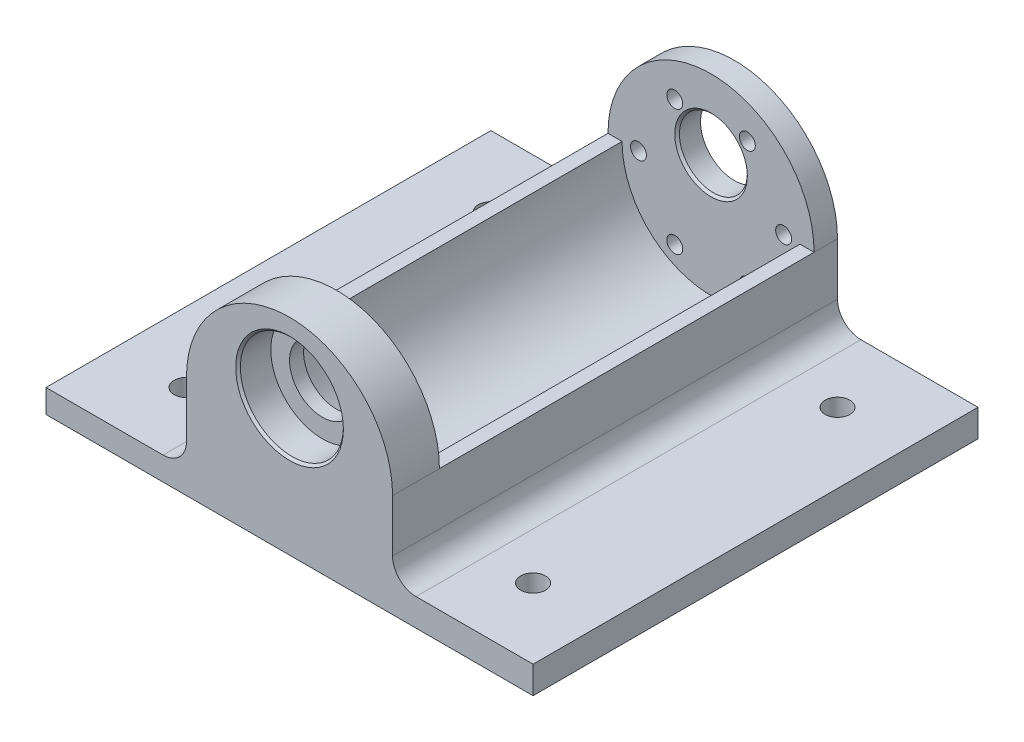
from build123d import *

# Parameters (mm, degrees)
SKETCH3_R                      = 7.25
BOSS_EXTRUDE1_DEPTH            = 5
M3_CLEARANCE_HOLE1_D           = 3.4
M3_CLEARANCE_HOLE1_CSINK_D     = 3.45
M3_CLEARANCE_HOLE1_CSINK_ANGLE = 90
BOSS_EXTRUDE2_DEPTH            = 80
BOSS_EXTRUDE3_DEPTH            = 10
SKETCH16_R                     = 11
CUT_EXTRUDE1_DEPTH             = 7
CUT_EXTRUDE2_REACH             = 90
SKETCH17_R                     = 7
CHAMFER2_SIZE                  = 0.5
CHAMFER3_SIZE                  = 0.5
SKETCH18_W                     = 95
SKETCH18_H                     = 5.838314525
BOSS_EXTRUDE5_DEPTH            = 30
SKETCH21_W                     = 95
SKETCH21_H                     = 5
BOSS_EXTRUDE6_DEPTH            = 30
FILLET1_R                      = 5
M5_CLEARANCE_SLOT1_D           = 5.3


with BuildPart() as part:
    # Sketch3 → Boss-Extrude1 (new body)
    with BuildSketch(Plane.XY):
        with BuildLine():
            Line((22, 0), (22, -22))
            Line((22, -22), (-22, -22))
            Line((-22, -22), (-22, 0))
            ThreePointArc((-22, 0), (0, 22), (22, 0))
        make_face()
        with Locations((0, 7)):
            Circle(SKETCH3_R, mode=Mode.SUBTRACT)
    extrude(amount=BOSS_EXTRUDE1_DEPTH)

    # M3 Clearance Hole1 (through all)
    with Locations(Plane(origin=(0, 0, 0), x_dir=(-1, 0, 0), z_dir=(0, 0, -1))):
        with Locations((-15.5, 0), (15.5, 0), (7.75, 13.423393759), (-7.75, 13.423393759), (-7.75, -13.423393759), (7.75, -13.423393759)):
            CounterSinkHole(M3_CLEARANCE_HOLE1_D / 2, M3_CLEARANCE_HOLE1_CSINK_D / 2, counter_sink_angle=M3_CLEARANCE_HOLE1_CSINK_ANGLE)

    # Sketch7 → Boss-Extrude2 (add)
    with BuildSketch(Plane.XY.offset(5)):
        with BuildLine():
            Line((-19, 0), (-22, 0))
            Line((-22, 0), (-22, -22))
            Line((-22, -22), (22, -22))
            Line((22, -22), (22, 0))
            Line((22, 0), (19, 0))
            ThreePointArc((19, 0), (0, -19), (-19, 0))
        make_face()
    extrude(amount=BOSS_EXTRUDE2_DEPTH)

    # Sketch9 → Boss-Extrude3 (add)
    with BuildSketch(Plane.XY.offset(85)):
        with BuildLine():
            Line((22, 0), (22, -22))
            Line((22, -22), (-22, -22))
            Line((-22, -22), (-22, 0))
            ThreePointArc((-22, 0), (0, 22), (22, 0))
        make_face()
    extrude(amount=BOSS_EXTRUDE3_DEPTH)

    # Sketch16 → Cut-Extrude1 (cut)
    with BuildSketch(Plane.XY.offset(95)):
        with Locations((0, 7)):
            Circle(SKETCH16_R)
    extrude(amount=-CUT_EXTRUDE1_DEPTH, mode=Mode.SUBTRACT)

    # Sketch17 → Cut-Extrude2 (cut, up to next)
    with BuildSketch(Plane.XY.offset(88), mode=Mode.PRIVATE) as cut_extrude2_sk1:
        with Locations((0, 7)):
            Circle(SKETCH17_R)
    cut_extrude2_tool1 = extrude(cut_extrude2_sk1.sketch, amount=-CUT_EXTRUDE2_REACH, mode=Mode.PRIVATE) & part.part
    add(cut_extrude2_tool1.solids().sort_by_distance((0, 7, 88))[0], mode=Mode.SUBTRACT)

    # Chamfer2
    chamfer2_edges = [part.edges().sort_by_distance(p)[0] for p in [
        (-11, 7, 95),
    ]]
    chamfer(chamfer2_edges, length=CHAMFER2_SIZE)

    # Chamfer3
    chamfer3_edges = [part.edges().sort_by_distance(p)[0] for p in [
        (-7.25, 7, 5),
    ]]
    chamfer(chamfer3_edges, length=CHAMFER3_SIZE)

    # Sketch18 → Boss-Extrude5 (add)
    with BuildSketch(Plane(origin=(22, 0, 0), x_dir=(0, 0, -1), z_dir=(1, 0, 0))):
        with Locations((-47.5, -19.080842737)):
            Rectangle(SKETCH18_W, SKETCH18_H)
    extrude(amount=BOSS_EXTRUDE5_DEPTH)

    # Sketch21 → Boss-Extrude6 (add)
    with BuildSketch(Plane.ZY.offset(22)):
        with Locations((47.5, -19.5)):
            Rectangle(SKETCH21_W, SKETCH21_H)
    extrude(amount=BOSS_EXTRUDE6_DEPTH)

    # Fillet1
    fillet1_edges = [part.edges().sort_by_distance(p)[0] for p in [
        (22, -16.161685475, 47.5),
        (-22, -17, 47.5),
    ]]
    fillet(fillet1_edges, radius=FILLET1_R)

    # M5 Clearance Slot1 (through all)
    with Locations(Plane(origin=(0, -22, 0), x_dir=(-1, 0, 0), z_dir=(0, -1, 0))):
        with Locations((37, -80), (-37, -80), (-37, -15), (37, -15)):
            Hole(M5_CLEARANCE_SLOT1_D / 2)


solid = part.part
